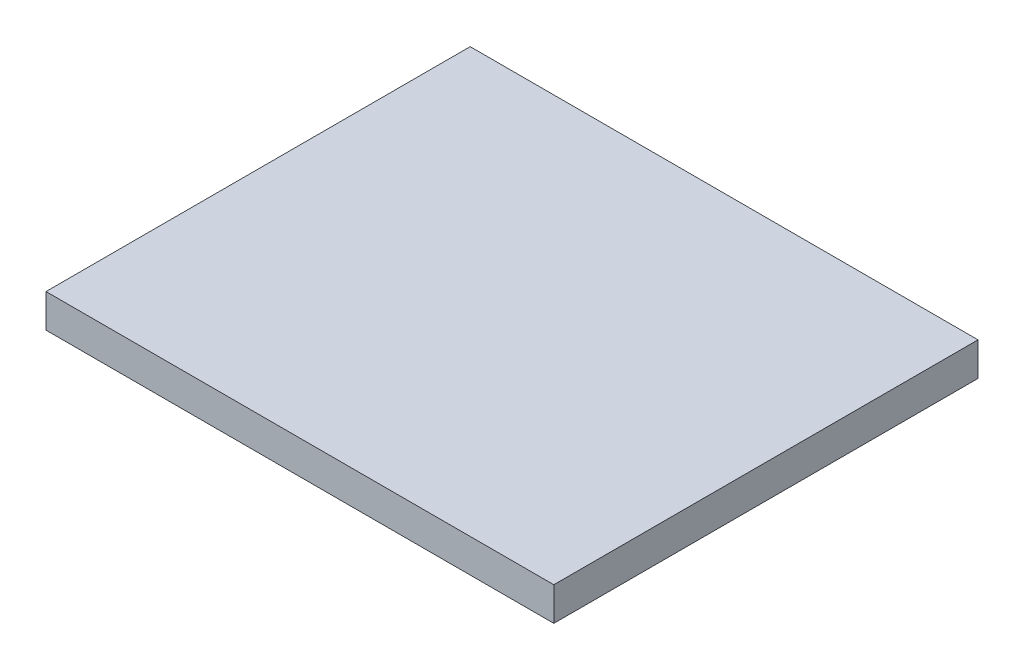
from build123d import *

# Parameters (mm, degrees)
SKETCH2_W           = 8.5
SKETCH2_H           = 7.1
BOSS_EXTRUDE1_DEPTH = 0.56


with BuildPart() as part:
    # Sketch2 → Boss-Extrude1 (new body)
    with BuildSketch(Plane(origin=(0, 0, 0), x_dir=(1, 0, 0), z_dir=(0, 1, 0))):
        with Locations((-3.442817656, -0.123886743)):
            Rectangle(SKETCH2_W, SKETCH2_H)
    extrude(amount=BOSS_EXTRUDE1_DEPTH)


solid = part.part
